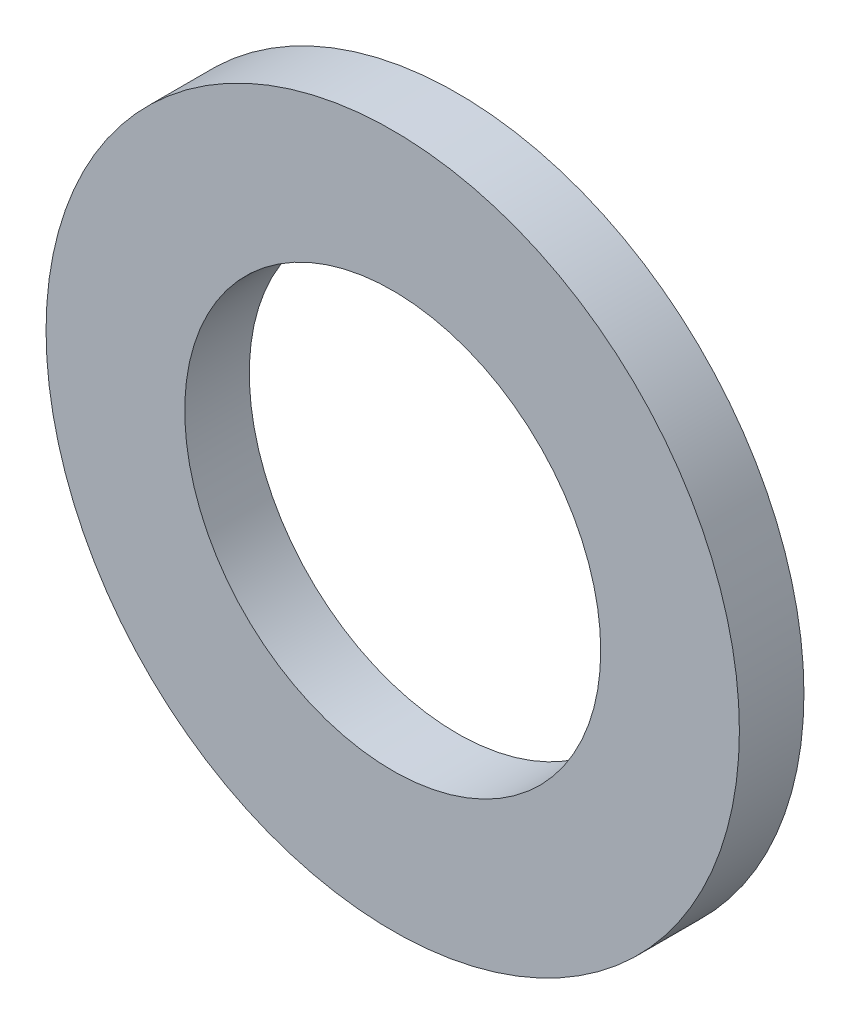
from build123d import *

# Parameters (mm, degrees)
SKETCH1_R           = 12.7
SKETCH1_R_2         = 7.62
BOSS_EXTRUDE1_DEPTH = 2.36474


with BuildPart() as part:
    # Sketch1 → Boss-Extrude1 (new body)
    with BuildSketch(Plane.XY):
        Circle(SKETCH1_R)
        Circle(SKETCH1_R_2, mode=Mode.SUBTRACT)
    extrude(amount=BOSS_EXTRUDE1_DEPTH)


solid = part.part
